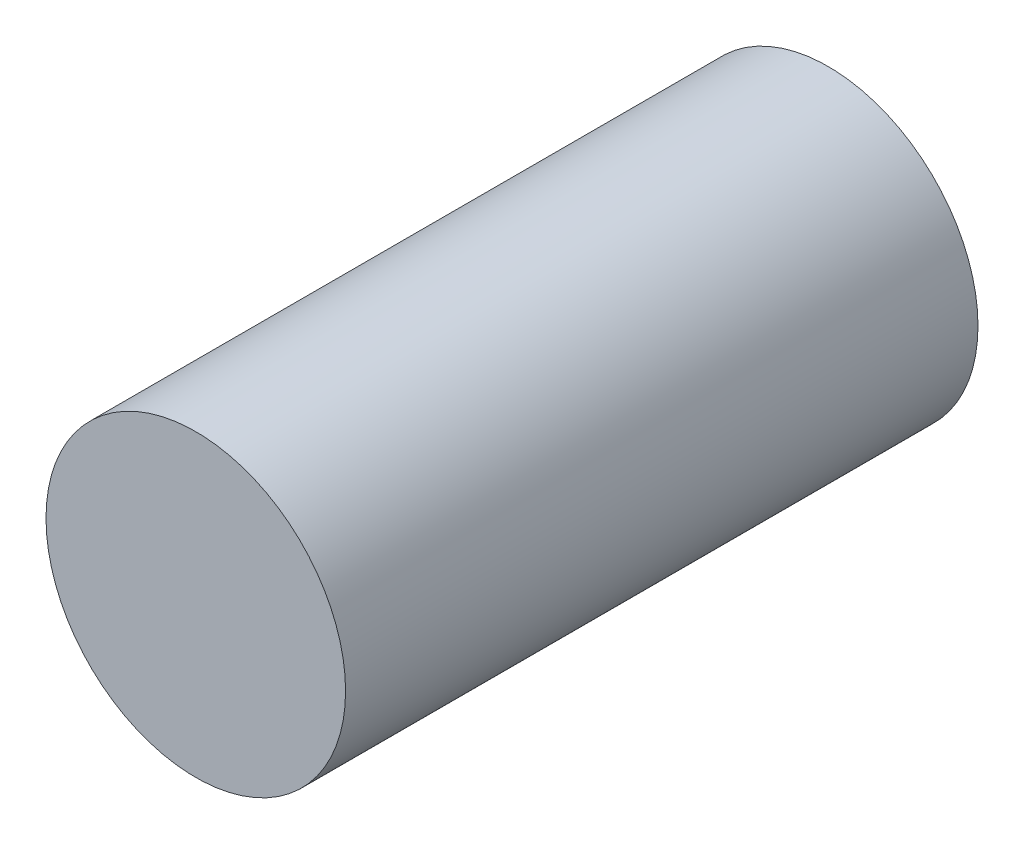
from build123d import *

# Parameters (mm, degrees)
SKETCH1_R           = 18
BOSS_EXTRUDE1_DEPTH = 76


with BuildPart() as part:
    # Sketch1 → Boss-Extrude1 (new body)
    with BuildSketch(Plane.XY):
        Circle(SKETCH1_R)
    extrude(amount=-BOSS_EXTRUDE1_DEPTH)


solid = part.part
